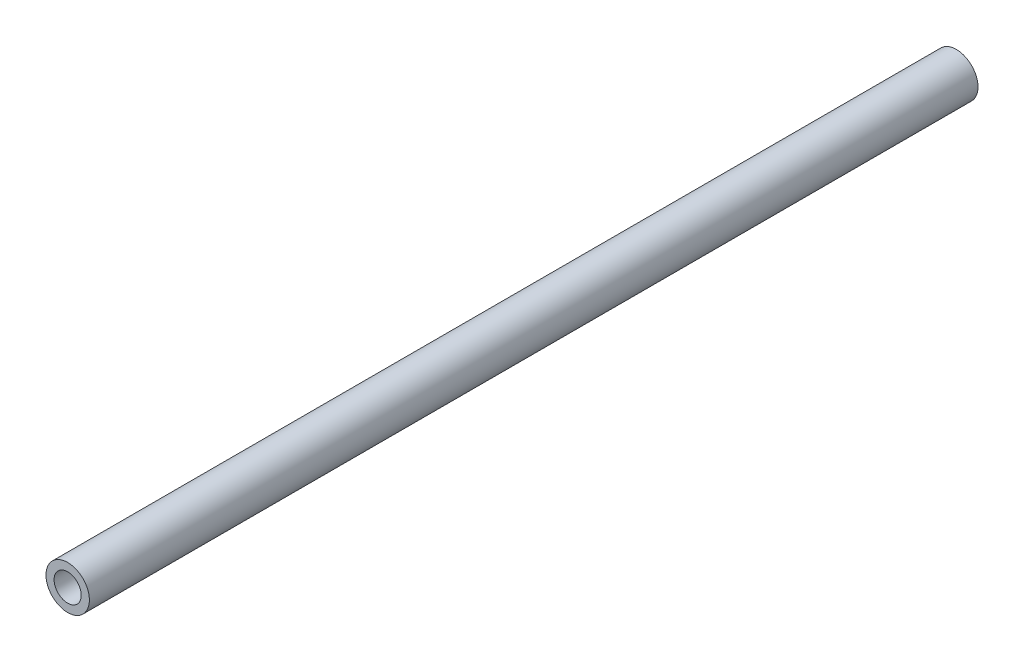
from build123d import *

# Parameters (mm, degrees)
SKETCH1_R           = 8.55
SKETCH1_R_2         = 5.35
BOSS_EXTRUDE1_DEPTH = 350


with BuildPart() as part:
    # Sketch1 → Boss-Extrude1 (new body)
    with BuildSketch(Plane.XY):
        Circle(SKETCH1_R)
        Circle(SKETCH1_R_2, mode=Mode.SUBTRACT)
    extrude(amount=-BOSS_EXTRUDE1_DEPTH)


solid = part.part
